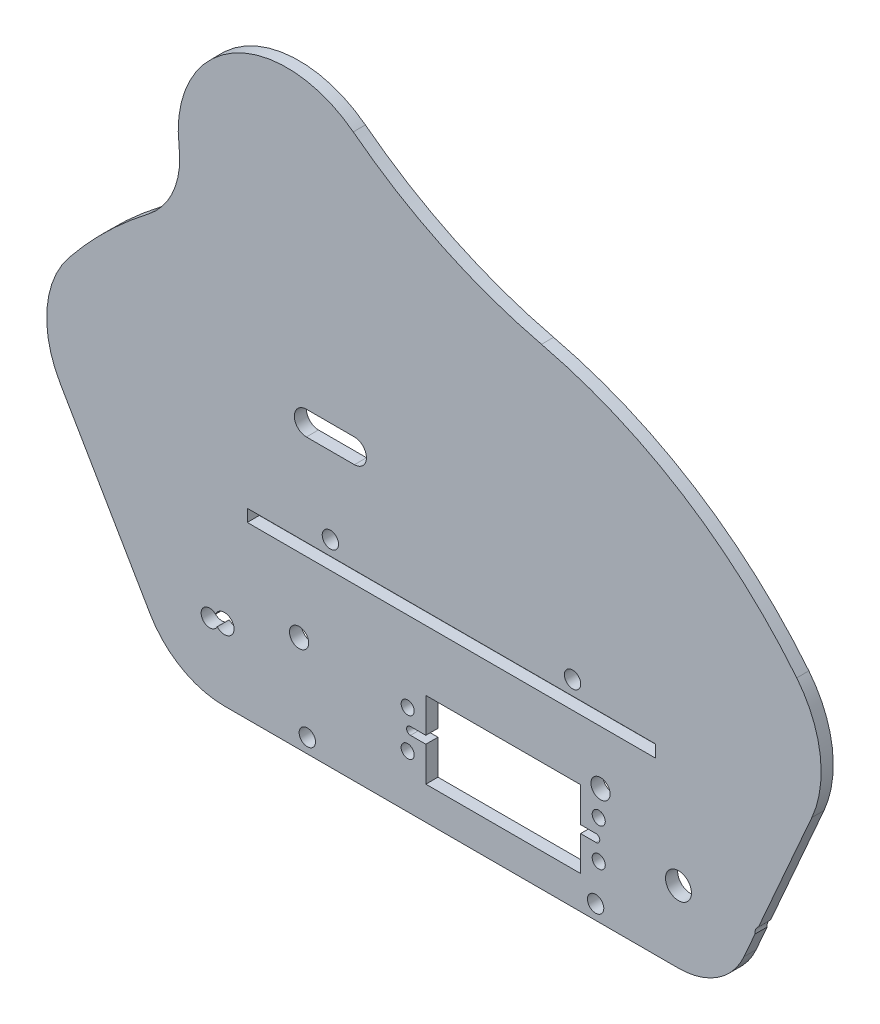
from build123d import *

# Parameters (mm, degrees)
SKETCH1_R           = 3.429
SKETCH1_R_2         = 2.54
BOSS_EXTRUDE1_DEPTH = 3.2004
SKETCH2_R           = 2.159
CUT_EXTRUDE1_DEPTH  = 3.2004
SKETCH5_R           = 1.7272
SKETCH5_W           = 40.894
SKETCH5_H           = 20.32
CUT_EXTRUDE3_DEPTH  = 4.2004
CUT_EXTRUDE4_DEPTH  = 3.2004
CUT_EXTRUDE8_DEPTH  = 3.2004
SKETCH11_W          = 107.95
SKETCH11_H          = 3.2512
CUT_EXTRUDE9_DEPTH  = 3.2004
SKETCH12_R          = 2.2479
CUT_EXTRUDE10_DEPTH = 3.2004
BOSS_EXTRUDE2_DEPTH = 3.2004


with BuildPart() as part:
    # Sketch1 → Boss-Extrude1 (new body)
    with BuildSketch(Plane.XY):
        with BuildLine():
            Line((0, 0), (120.015, 0))
            ThreePointArc((120.015, 0), (130.351788397, 3.075697789), (137.325636158, 11.302152593))
            Line((137.325636158, 11.302152593), (155.257499999, 52.11572))
            ThreePointArc((155.257499999, 52.11572), (157.462147967, 67.664529981), (151.26869294, 82.095991421))
            ThreePointArc((151.26869294, 82.095991421), (55.081013593, 128.103082212), (-41.106665754, 82.095991421))
            ThreePointArc((-41.106665754, 82.095991421), (-46.904819593, 67.459968464), (-43.385473773, 52.11572))
            Line((-43.385473773, 52.11572), (-19.648099871, 11.302152593))
            ThreePointArc((-19.648099871, 11.302152593), (-11.333429333, 3.027112684), (0, 0))
        make_face()
        with Locations((120.015, 18.90776)):
            Circle(SKETCH1_R, mode=Mode.SUBTRACT)
        with Locations((0, 18.90776)):
            Circle(SKETCH1_R_2, mode=Mode.SUBTRACT)
        with Locations((19.734727626, 25.566426992)):
            Circle(SKETCH1_R_2, mode=Mode.SUBTRACT)
        with Locations((99.400822531, 30.809360911)):
            Circle(SKETCH1_R_2, mode=Mode.SUBTRACT)
    extrude(amount=BOSS_EXTRUDE1_DEPTH)

    # Sketch2 → Cut-Extrude1 (cut)
    with BuildSketch(Plane(origin=(0, 0, 0), x_dir=(-1, 0, 0), z_dir=(0, 0, -1))):
        with Locations((-92.0115, 52.115719911)):
            Circle(SKETCH2_R)
        with Locations((-28.0035, 52.115719911)):
            Circle(SKETCH2_R)
        with Locations((-98.1075, 3.81)):
            Circle(SKETCH2_R)
        with Locations((-21.9075, 3.81)):
            Circle(SKETCH2_R)
    extrude(amount=-CUT_EXTRUDE1_DEPTH, mode=Mode.SUBTRACT)

    # Sketch5 → Cut-Extrude3 (cut, through all)
    with BuildSketch(Plane(origin=(0, 0, 0), x_dir=(-1, 0, 0), z_dir=(0, 0, -1))):
        with Locations((-98.932021292, 23.90776)):
            Circle(SKETCH5_R)
        with Locations((-48.432021292, 13.90776)):
            Circle(SKETCH5_R)
        with Locations((-48.432021292, 23.90776)):
            Circle(SKETCH5_R)
        with Locations((-98.932021292, 13.90776)):
            Circle(SKETCH5_R)
        with Locations((-73.682021292, 18.90776)):
            Rectangle(SKETCH5_W, SKETCH5_H)
    extrude(amount=-CUT_EXTRUDE3_DEPTH, mode=Mode.SUBTRACT)

    # Sketch6 → Cut-Extrude4 (cut)
    with BuildSketch(Plane.XY.offset(3.2004)):
        with BuildLine():
            Line((49.171021292, 19.92376), (53.235021292, 19.92376))
            Line((53.235021292, 19.92376), (53.235021292, 17.89176))
            Line((53.235021292, 17.89176), (49.171021292, 17.89176))
            ThreePointArc((49.171021292, 17.89176), (48.155021292, 18.90776), (49.171021292, 19.92376))
        make_face()
        with BuildLine():
            Line((94.129021292, 19.92376), (98.193021292, 19.92376))
            ThreePointArc((98.193021292, 19.92376), (99.209021292, 18.90776), (98.193021292, 17.89176))
            Line((98.193021292, 17.89176), (94.129021292, 17.89176))
            Line((94.129021292, 17.89176), (94.129021292, 19.92376))
        make_face()
    extrude(amount=-CUT_EXTRUDE4_DEPTH, mode=Mode.SUBTRACT)

    # Sketch10 → Cut-Extrude8 (cut)
    with BuildSketch(Plane(origin=(0, 0, 0), x_dir=(-1, 0, 0), z_dir=(0, 0, -1))):
        with BuildLine():
            Line((-34.3535, 78.785719911), (-21.6535, 78.785719911))
            ThreePointArc((-21.6535, 78.785719911), (-18.4785, 75.610719911), (-21.6535, 72.435719911))
            Line((-21.6535, 72.435719911), (-34.3535, 72.435719911))
            ThreePointArc((-34.3535, 72.435719911), (-37.5285, 75.610719911), (-34.3535, 78.785719911))
        make_face()
    extrude(amount=-CUT_EXTRUDE8_DEPTH, mode=Mode.SUBTRACT)

    # Sketch11 → Cut-Extrude9 (cut)
    with BuildSketch(Plane(origin=(0, 0, 0), x_dir=(-1, 0, 0), z_dir=(0, 0, -1))):
        with Locations((-60.0075, 46.680119911)):
            Rectangle(SKETCH11_W, SKETCH11_H)
    extrude(amount=-CUT_EXTRUDE9_DEPTH, mode=Mode.SUBTRACT)

    # Sketch12 → Cut-Extrude10 (cut)
    with BuildSketch(Plane(origin=(0, 0, 0), x_dir=(-1, 0, 0), z_dir=(0, 0, -1))):
        with Locations((-142.479014632, 18.224067698)):
            Circle(SKETCH12_R)
        with Locations((3.91433865, 18.224067698)):
            Circle(SKETCH12_R)
    extrude(amount=-CUT_EXTRUDE10_DEPTH, mode=Mode.SUBTRACT)

    # Sketch13 → Boss-Extrude2 (add)
    with BuildSketch(Plane(origin=(0, 0, 0), x_dir=(-1, 0, 0), z_dir=(0, 0, -1))):
        with BuildLine():
            Line((-83.804619012, 124.717903232), (20.105573885, 102.592791936))
            ThreePointArc((20.105573885, 102.592791936), (13.448555565, 111.243555983), (11.985080528, 122.060665224))
            ThreePointArc((11.985080528, 122.060665224), (-2.230930753, 150.611793246), (-34.052645197, 148.457639581))
            ThreePointArc((-34.052645197, 148.457639581), (-57.67418009, 133.958784174), (-83.804619012, 124.717903232))
        make_face()
    extrude(amount=-BOSS_EXTRUDE2_DEPTH)


solid = part.part
